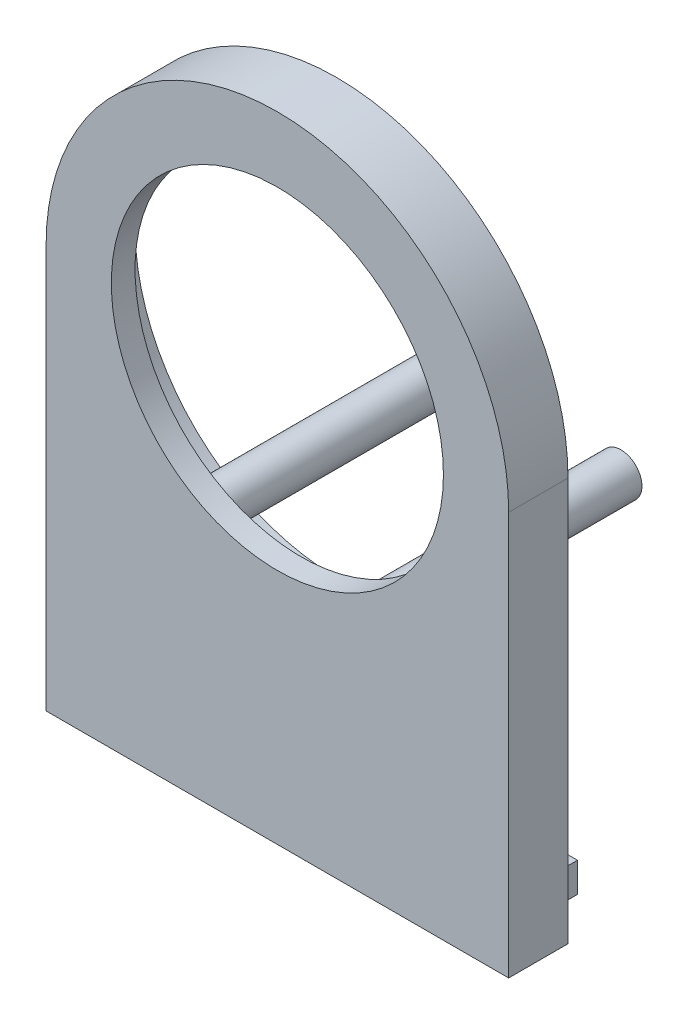
from build123d import *

# Parameters (mm, degrees)
SKETCH1_R                = 43.18
SKETCH1_R_2              = 35.56
BOSS_EXTRUDE1_DEPTH      = 5.08
SKETCH1_4_R              = 49.53
SKETCH1_4_R_2            = 43.18
BOSS_EXTRUDE2_DEPTH      = 12.7
BOSS_EXTRUDE3_DEPTH      = 12.7
SKETCH3_W                = 10.16
SKETCH3_H                = 6.35
BOSS_EXTRUDE4_DEPTH      = 90.932
BOSS_EXTRUDE5_DEPTH      = 43.18
BOSS_EXTRUDE5_DEPTH_BACK = 8.89
SKETCH4_R                = 4.495372053


with BuildPart() as part:
    # Sketch1 → Boss-Extrude1 (new body)
    with BuildSketch(Plane.XY):
        Circle(SKETCH1_R)
        Circle(SKETCH1_R_2, mode=Mode.SUBTRACT)
    extrude(amount=-BOSS_EXTRUDE1_DEPTH)

    # Sketch1_4 → Boss-Extrude2 (add)
    with BuildSketch(Plane.XY):
        Circle(SKETCH1_4_R)
        Circle(SKETCH1_4_R_2, mode=Mode.SUBTRACT)
    extrude(amount=-BOSS_EXTRUDE2_DEPTH)

    # Sketch2 → Boss-Extrude3 (add)
    with BuildSketch(Plane.XY):
        with BuildLine():
            ThreePointArc((49.53, 0), (0, -49.53), (-49.53, 0))
            Line((-49.53, 0), (-49.53, -49.53))
            Line((-49.53, -49.53), (-49.53, -86.36))
            Line((-49.53, -86.36), (0, -86.36))
            Line((0, -86.36), (49.53, -86.36))
            Line((49.53, -86.36), (49.53, 0))
        make_face()
    extrude(amount=-BOSS_EXTRUDE3_DEPTH)

    # Sketch3 → Boss-Extrude4 (add)
    with BuildSketch(Plane.ZY.offset(49.53)):
        with Locations((-17.78, -83.185)):
            Rectangle(SKETCH3_W, SKETCH3_H)
    extrude(amount=-BOSS_EXTRUDE4_DEPTH)

    # Sketch4 → Boss-Extrude5 (add, two sides: drawn at the far end of the back side and taken through both)
    with BuildSketch(Plane(origin=(0, 0, -12.7), x_dir=(-1, 0, 0), z_dir=(0, 0, -1)).offset(-BOSS_EXTRUDE5_DEPTH_BACK)):
        with Locations((-17.696483248, -36.755496611)):
            Circle(SKETCH4_R)
        with Locations((20.052531589, -36.755496611)):
            Circle(SKETCH4_R)
    extrude(amount=BOSS_EXTRUDE5_DEPTH + BOSS_EXTRUDE5_DEPTH_BACK)


solid = part.part
